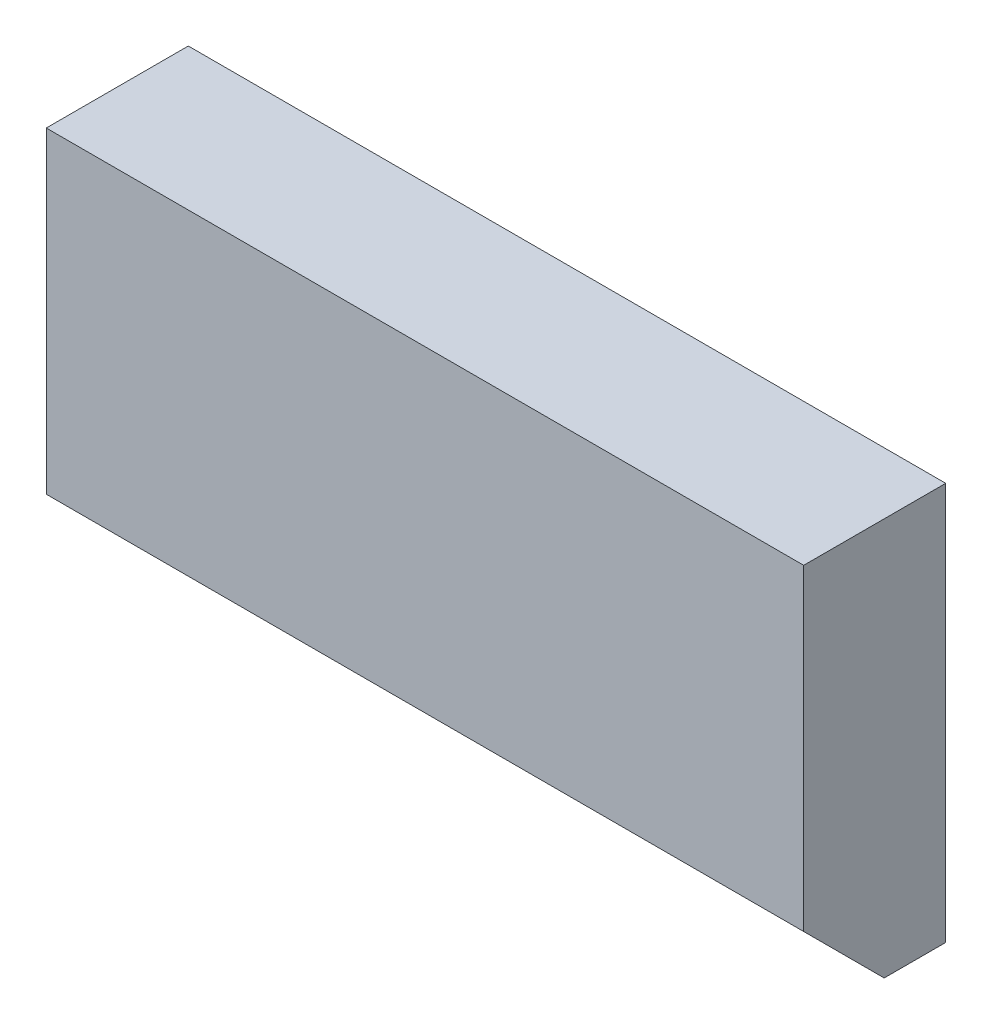
from build123d import *

# Parameters (mm, degrees)
SKETCH_1_W      = 16
SKETCH_1_H      = 8.7
EXTRUDE_1_DEPTH = 3
CHAMFER_3_SIZE  = 2
CHAMFER_4_SIZE  = 0.3


with BuildPart() as part:
    # Эскиз1 → Вытянуть1 (new body)
    with BuildSketch(Plane.XY):
        with Locations((8, 4.35)):
            Rectangle(SKETCH_1_W, SKETCH_1_H)
    extrude(amount=EXTRUDE_1_DEPTH)

    # Фаска3
    chamfer_3_edges = [part.edges().sort_by_distance(p)[0] for p in [
        (8, 0, 3),
    ]]
    chamfer(chamfer_3_edges, length=CHAMFER_3_SIZE)

    # Фаска4
    chamfer_4_edges = [part.edges().sort_by_distance(p)[0] for p in [
        (16, 0, 0.5),
    ]]
    chamfer(chamfer_4_edges, length=CHAMFER_4_SIZE)


solid = part.part
